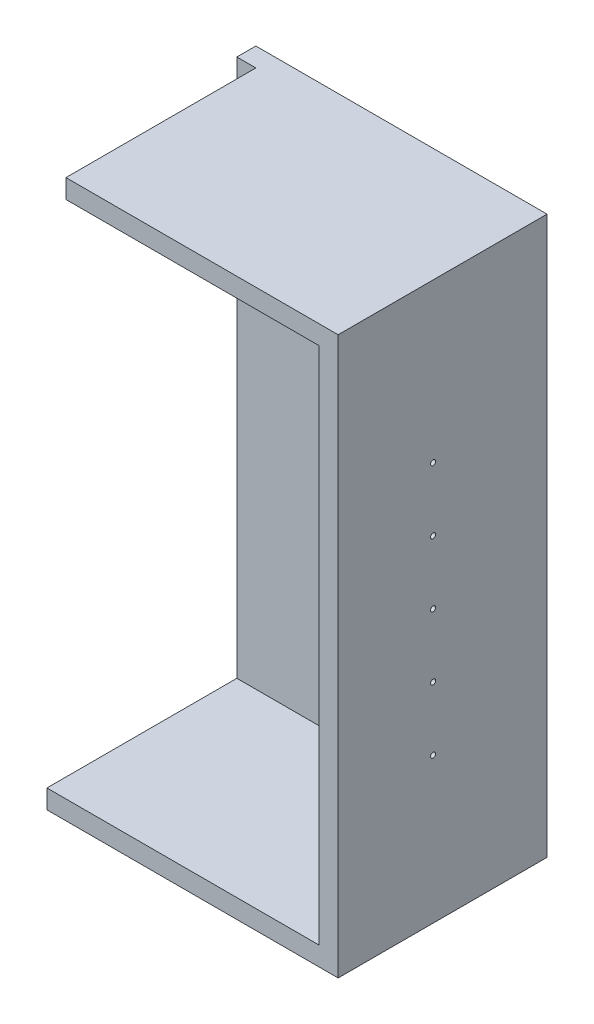
from build123d import *

# Parameters (mm, degrees)
SKETCH1_W           = 460
SKETCH1_H           = 880
SKETCH1_W_2         = 400
SKETCH1_H_2         = 820
BOSS_EXTRUDE1_DEPTH = 300
SKETCH2_W           = 460
SKETCH2_H           = 880
BOSS_EXTRUDE2_DEPTH = 30
SKETCH3_R           = 4
CUT_EXTRUDE1_DEPTH  = 460
SKETCH4_W           = 30
SKETCH4_H           = 850
CUT_EXTRUDE2_DEPTH  = 300


with BuildPart() as part:
    # Sketch1 → Boss-Extrude1 (new body)
    with BuildSketch(Plane.XY):
        Rectangle(SKETCH1_W, SKETCH1_H)
        Rectangle(SKETCH1_W_2, SKETCH1_H_2, mode=Mode.SUBTRACT)
    extrude(amount=BOSS_EXTRUDE1_DEPTH)

    # Sketch2 → Boss-Extrude2 (add)
    with BuildSketch(Plane(origin=(0, 0, 0), x_dir=(-1, 0, 0), z_dir=(0, 0, -1))):
        Rectangle(SKETCH2_W, SKETCH2_H)
    extrude(amount=BOSS_EXTRUDE2_DEPTH)

    # Sketch3 → Cut-Extrude1 (cut)
    with BuildSketch(Plane(origin=(230, 0, 0), x_dir=(0, 0, -1), z_dir=(1, 0, 0))):
        with Locations((-150, 190)):
            Circle(SKETCH3_R)
        with Locations((-150, 90)):
            Circle(SKETCH3_R)
        with Locations((-150, -10)):
            Circle(SKETCH3_R)
        with Locations((-150, -110)):
            Circle(SKETCH3_R)
        with Locations((-150, -210)):
            Circle(SKETCH3_R)
    extrude(amount=-CUT_EXTRUDE1_DEPTH, mode=Mode.SUBTRACT)

    # Sketch4 → Cut-Extrude2 (cut)
    with BuildSketch(Plane.XY.offset(300)):
        with Locations((-215, 15)):
            Rectangle(SKETCH4_W, SKETCH4_H)
    extrude(amount=-CUT_EXTRUDE2_DEPTH, mode=Mode.SUBTRACT)


solid = part.part
